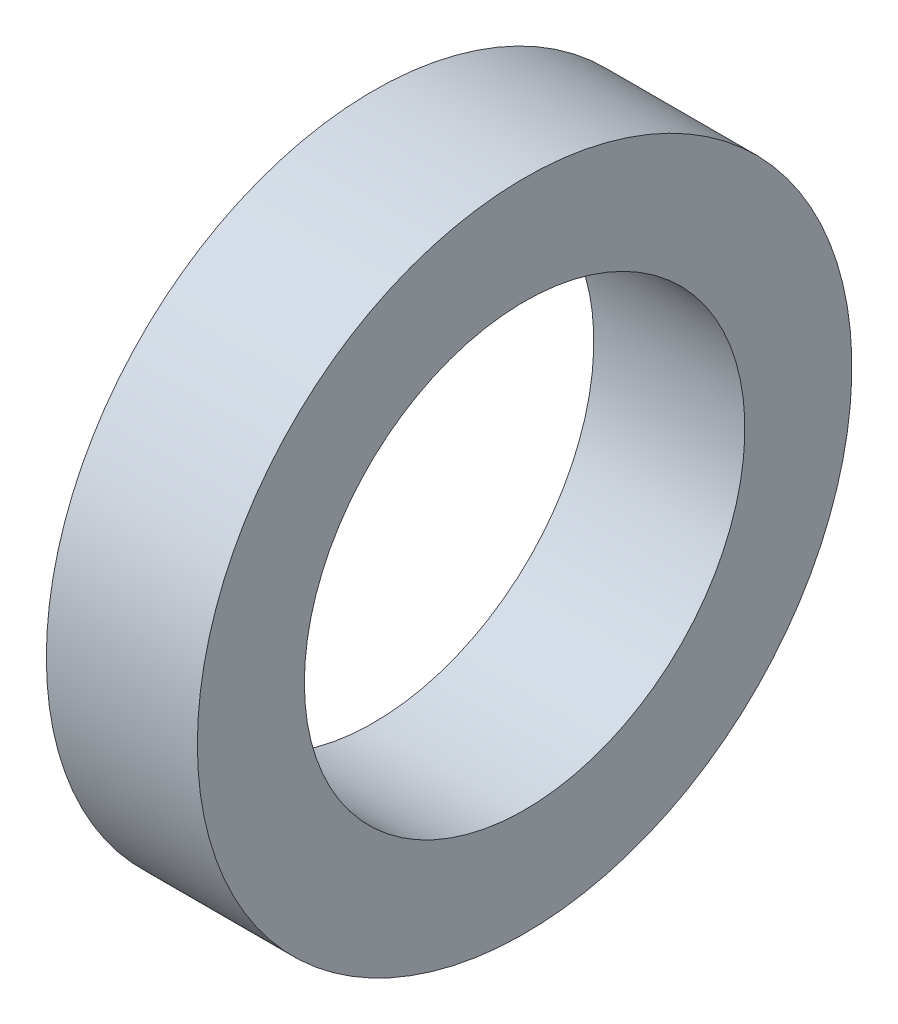
from build123d import *

# Parameters (mm, degrees)
SKETCH1_W = 12
SKETCH1_H = 8.5


with BuildPart() as part:
    # Sketch1 → Revolve1 (revolve)
    with BuildSketch(Plane.XY):
        with Locations((6, 21.75)):
            Rectangle(SKETCH1_W, SKETCH1_H)
    revolve(axis=Axis((0, 0, 0), (1, 0, 0)))


solid = part.part
